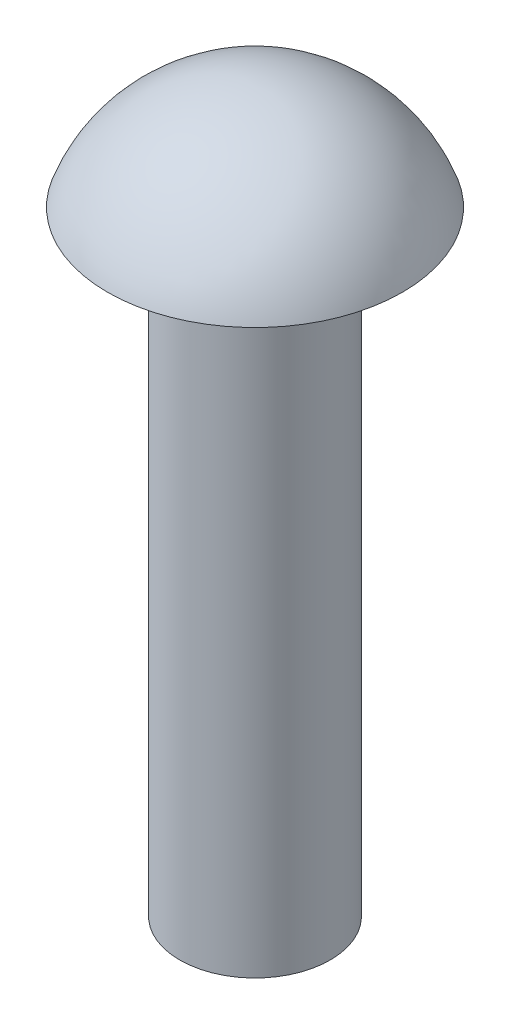
from build123d import *


with BuildPart() as part:
    # Sketch1 → Revolve2 (revolve)
    with BuildSketch(Plane(origin=(0, 0, 0), x_dir=(0, 0, -1), z_dir=(1, 0, 0))):
        with BuildLine():
            Line((0, -11.7), (1.225, -11.7))
            Line((1.225, -11.7), (1.225, -1.7))
            Line((1.225, -1.7), (2.4, -1.7))
            ThreePointArc((2.4, -1.7), (1.470544117, -0.468055364), (0, 0))
            Line((0, 0), (0, -11.7))
        make_face()
    revolve(axis=Axis((0, 0, 0), (0, -1, 0)))


solid = part.part
